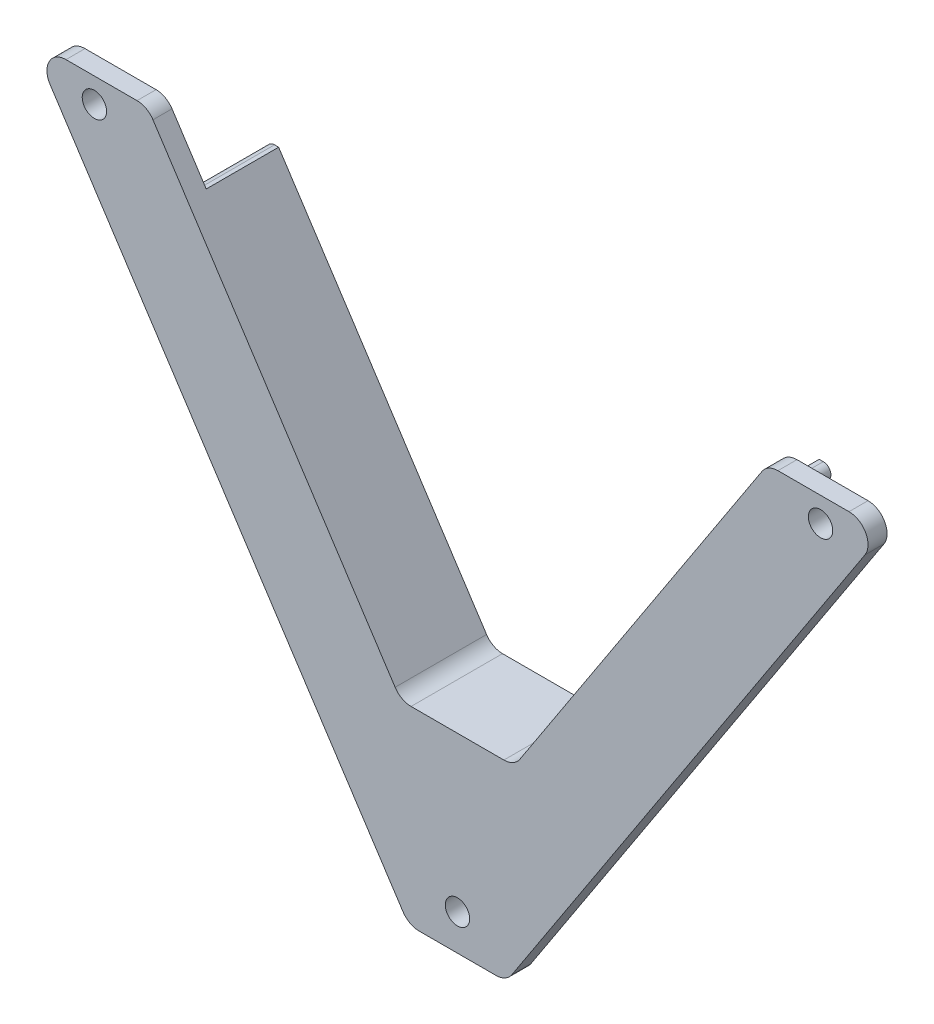
from build123d import *

# Parameters (mm, degrees)
BOSS_EXTRU_1_DEPTH      = 2.5
ESQUISSE2_R             = 1.6
ENL_V_MAT_EXTRU_1_DEPTH = 3.5
BOSS_EXTRU_2_DEPTH      = 9.5
CONG_2_R                = 1
CONG_1_R                = 2.5
ESQUISSE4_R             = 1.6
ENL_V_MAT_EXTRU_2_DEPTH = 13


with BuildPart() as part:
    # Esquisse1 → Boss.-Extru.1 (new body)
    with BuildSketch(Plane.XY):
        Polygon((-6.4, 0), (6.11755814, 0), (6.4, 0), (56, 75.87), (40.7, 75.87), (7.443745881, 25), (-7.443745881, 25), (-40.7, 75.87), (-56, 75.87), align=None)
    extrude(amount=BOSS_EXTRU_1_DEPTH)

    # Esquisse2 → Enlèv. mat.-Extru.1 (cut, through all)
    with BuildSketch(Plane.XY.offset(2.5)):
        with Locations((0, 4.7)):
            Circle(ESQUISSE2_R)
    extrude(amount=-ENL_V_MAT_EXTRU_1_DEPTH, mode=Mode.SUBTRACT)

    # Esquisse3 → Boss.-Extru.2 (add)
    with BuildSketch(Plane(origin=(0, 0, 0), x_dir=(-1, 0, 0), z_dir=(0, 0, -1))):
        Polygon((-35.470001318, 67.87), (-7.443745881, 25), (7.443745881, 25), (35.470001318, 67.87), (37.859468913, 67.87), (8.525713806, 23), (-8.525713806, 23), (-37.859468913, 67.87), align=None)
    extrude(amount=BOSS_EXTRU_2_DEPTH)

    # Congé2
    cong_2_edges = [part.edges().sort_by_distance(p)[0] for p in [
        (37.859468913, 67.87, -4.75),
        (-37.859468913, 67.87, -4.75),
    ]]
    fillet(cong_2_edges, radius=CONG_2_R)

    # Congé1
    cong_1_edges = [part.edges().sort_by_distance(p)[0] for p in [
        (56, 75.87, 1.25),
        (6.4, 0, 1.25),
        (-6.4, 0, 1.25),
        (-56, 75.87, 1.25),
        (-40.7, 75.87, 1.25),
        (-7.443745881, 25, -3.5),
        (7.443745881, 25, -3.5),
        (40.7, 75.87, 1.25),
    ]]
    fillet(cong_1_edges, radius=CONG_1_R)

    # Esquisse4 → Enlèv. mat.-Extru.2 (cut, through all)
    with BuildSketch(Plane.XY.offset(2.5)):
        with Locations((47.647073462, 72.644280098)):
            Circle(ESQUISSE4_R)
        with Locations((-47.647073462, 72.644280098)):
            Circle(ESQUISSE4_R)
    extrude(amount=-ENL_V_MAT_EXTRU_2_DEPTH, mode=Mode.SUBTRACT)


solid = part.part
